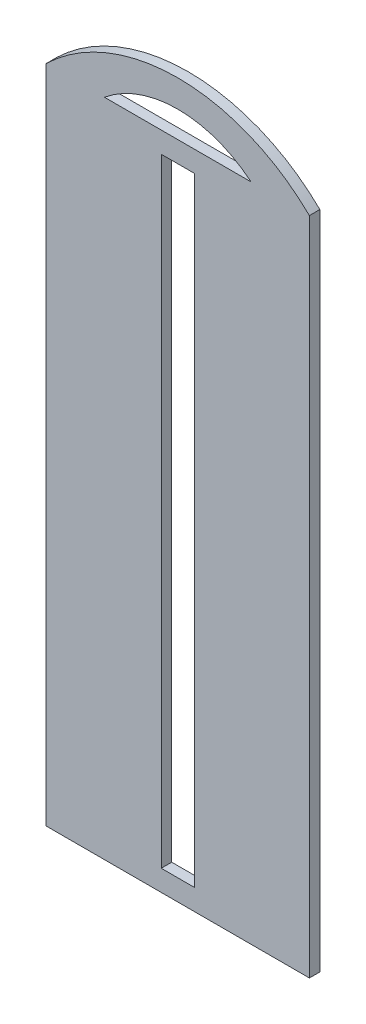
from build123d import *

# Parameters (mm, degrees)
SKETCH1_W           = 10
SKETCH1_H           = 187.325
BOSS_EXTRUDE1_DEPTH = 3.175


with BuildPart() as part:
    # Sketch1 → Boss-Extrude1 (new body)
    with BuildSketch(Plane.XY):
        with BuildLine():
            Line((0, 0), (79.756, 0))
            Line((79.756, 0), (79.756, 200.025))
            ThreePointArc((79.756, 200.025), (39.878, 216.237637896), (0, 200.025))
            Line((0, 200.025), (0, 0))
        make_face()
        with BuildLine():
            Line((17.653, 200.025), (62.103, 200.025))
            ThreePointArc((62.103, 200.025), (39.878, 208.009231637), (17.653, 200.025))
        make_face(mode=Mode.SUBTRACT)
        with Locations((39.878, 100.0125)):
            Rectangle(SKETCH1_W, SKETCH1_H, mode=Mode.SUBTRACT)
    extrude(amount=-BOSS_EXTRUDE1_DEPTH)


solid = part.part
